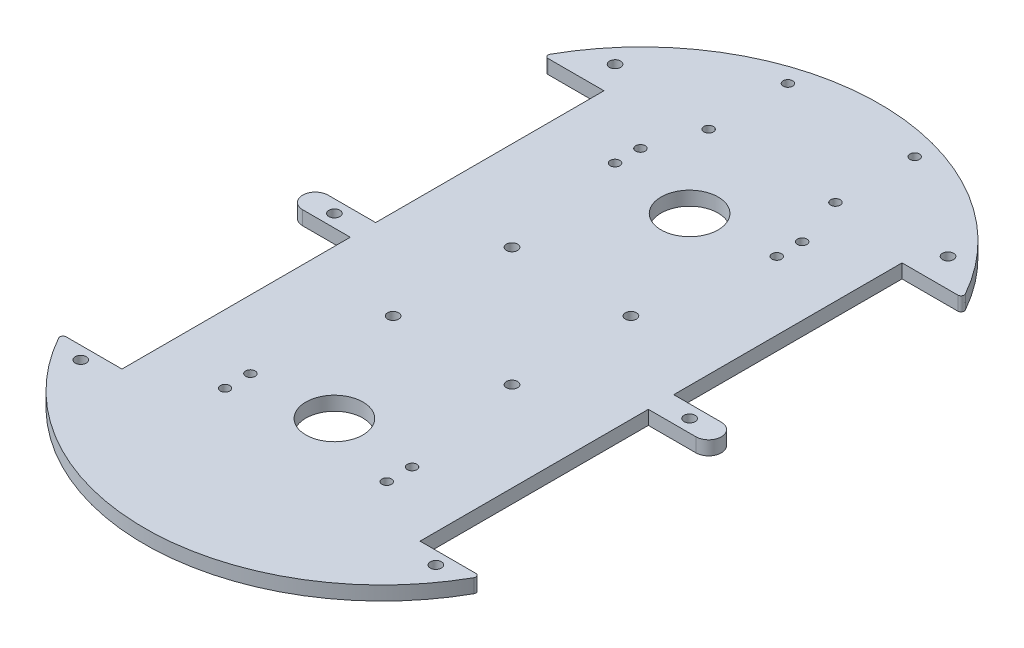
from build123d import *

# Parameters (mm, degrees)
SKETCH2_W                  = 132
SKETCH2_H                  = 232
PLATE_SIZE_DEPTH           = 4.4
SKETCH4_OUTSIDE_W          = 187.392
SKETCH4_OUTSIDE_H          = 287.392
OUTER_PROFILE_DEPTH        = 5.4
M3_CLEARANCE_HOLE1_D       = 3.5
F_18_0_18_DIAMETER_HOLE4_D = 18
M3_CLEARANCE_HOLE2_D       = 3.5
M3_CLEARANCE_HOLE3_D       = 3
M3_CLEARANCE_HOLE4_D       = 3


with BuildPart() as part:
    # Sketch2 → Plate Size (new body)
    with BuildSketch(Plane(origin=(0, 0, 0), x_dir=(1, 0, 0), z_dir=(0, 1, 0))):
        Rectangle(SKETCH2_W, SKETCH2_H)
    extrude(amount=PLATE_SIZE_DEPTH)

    # Sketch4 outside → Outer Profile (cut, through all)
    with BuildSketch(Plane(origin=(0, 0, 0), x_dir=(1, 0, 0), z_dir=(0, 1, 0))):
        Rectangle(SKETCH4_OUTSIDE_W, SKETCH4_OUTSIDE_H)
        with BuildLine():
            Line((-64.599996007, 76), (-47, 76))
            Line((-47, 76), (-47, 4))
            Line((-47, 4), (-62, 4))
            ThreePointArc((-62, 4), (-66, 0), (-62, -4))
            Line((-62, -4), (-47, -4))
            Line((-47, -4), (-47, -76))
            Line((-47, -76), (-64.599996007, -76))
            ThreePointArc((-64.599996007, -76), (-65.462483305, -76.493921289), (-65.472968926, -77.487768677))
            ThreePointArc((-65.472968926, -77.487768677), (0, -115.905117871), (65.472968926, -77.487768677))
            ThreePointArc((65.472968926, -77.487768677), (65.462483305, -76.493921289), (64.599996007, -76))
            Line((64.599996007, -76), (47, -76))
            Line((47, -76), (47, -4))
            Line((47, -4), (62, -4))
            ThreePointArc((62, -4), (66, 0), (62, 4))
            Line((62, 4), (47, 4))
            Line((47, 4), (47, 76))
            Line((47, 76), (64.599996007, 76))
            ThreePointArc((64.599996007, 76), (65.462483305, 76.493921289), (65.472968926, 77.487768677))
            ThreePointArc((65.472968926, 77.487768677), (0, 115.905117871), (-65.472968926, 77.487768677))
            ThreePointArc((-65.472968926, 77.487768677), (-65.462483305, 76.493921289), (-64.599996007, 76))
        make_face(mode=Mode.SUBTRACT)
    extrude(amount=OUTER_PROFILE_DEPTH, mode=Mode.SUBTRACT)

    # M3 Clearance Hole1 (through all)
    with Locations(Plane.XZ):
        with Locations((-55.999996141, 80.000001937), (55.999996141, 80.000001937), (-52.5, -85), (52.5, -85), (-55.999996141, 0), (55.999996141, 0)):
            Hole(M3_CLEARANCE_HOLE1_D / 2)

    # Ø18.0 (18) Diameter Hole4 (through all)
    with Locations(Plane.XZ):
        with Locations((0, -56), (0, 56)):
            Hole(F_18_0_18_DIAMETER_HOLE4_D / 2)

    # M3 Clearance Hole2 (through all)
    with Locations(Plane.XZ):
        with Locations((18.75, -18.75), (-18.75, 18.75), (18.75, 18.75), (-18.75, -18.75)):
            Hole(M3_CLEARANCE_HOLE2_D / 2)

    # M3 Clearance Hole3 (through all)
    with Locations(Plane.XZ):
        with Locations((-25.5, -66.00000008), (25.5, 65.00000008), (-25.5, 65.00000008), (25.5, -66.00000008), (-25.5, -58.00000008), (25.5, -58.00000008), (25.5, 57.00000008), (-25.5, 57.00000008)):
            Hole(M3_CLEARANCE_HOLE3_D / 2)

    # M3 Clearance Hole4 (through all)
    with Locations(Plane.XZ):
        with Locations((-20, -107), (20, -107), (-20, -82), (20, -82)):
            Hole(M3_CLEARANCE_HOLE4_D / 2)


solid = part.part
